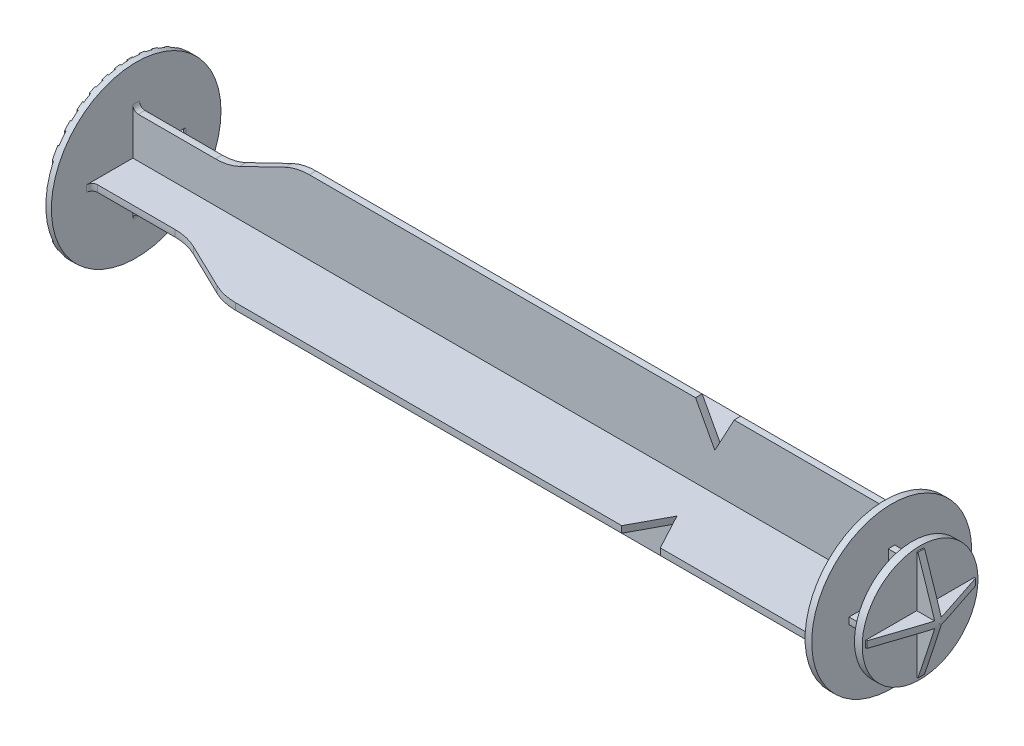
from build123d import *

# Parameters (mm, degrees)
SKETCH2_OUTSIDE_W   = 63.372
SKETCH2_OUTSIDE_H   = 63.372
CUT_EXTRUDE1_DEPTH  = 135.75
SKETCH3_OUTSIDE_W   = 63.372
SKETCH3_OUTSIDE_H   = 63.372
SKETCH3_OUTSIDE_W_2 = 1
SKETCH3_OUTSIDE_H_2 = 30.733735536
CUT_EXTRUDE2_DEPTH  = 0.2
SKETCH4_OUTSIDE_W   = 63.372
SKETCH4_OUTSIDE_H   = 63.372
CUT_EXTRUDE3_DEPTH  = 3.75
SKETCH5_OUTSIDE_W   = 63.372
SKETCH5_OUTSIDE_H   = 63.372
CUT_EXTRUDE4_DEPTH  = 3.5


with BuildPart() as part:
    # Sketch1 → Revolve1 (revolve)
    with BuildSketch(Plane.XY):
        with BuildLine():
            Line((0, 0), (0, 15.375))
            Line((0, 15.375), (1.2, 15.375))
            Line((1.2, 15.375), (1.2, 9))
            ThreePointArc((1.2, 9), (1.492893219, 8.292893219), (2.2, 8))
            Line((2.2, 8), (16.2, 8))
            ThreePointArc((16.2, 8), (18.430707535, 8.251977437), (20.548997476, 8.995211221))
            Line((20.548997476, 8.995211221), (28.851002524, 13.004788779))
            ThreePointArc((28.851002524, 13.004788779), (30.969292465, 13.748022563), (33.2, 14))
            Line((33.2, 14), (103.2, 14))
            Line((103.2, 14), (106.7, 7.5))
            Line((106.7, 7.5), (110.2, 14))
            Line((110.2, 14), (136.95, 14))
            Line((136.95, 14), (136.95, 14.5))
            Line((136.95, 14.5), (138.15, 14.5))
            Line((138.15, 14.5), (138.15, 7.75))
            Line((138.15, 7.75), (141.9, 7.75))
            Line((141.9, 7.75), (141.9, 10.5))
            Line((141.9, 10.5), (143.3, 10.5))
            Line((143.3, 10.5), (146.8, 0))
            Line((146.8, 0), (0, 0))
        make_face()
    revolve(axis=Axis((146.8, 0, 0), (-1, 0, 0)))

    # Sketch2 outside → Cut-Extrude1 (cut)
    with BuildSketch(Plane(origin=(1.2, 0, 0), x_dir=(0, 0, -1), z_dir=(1, 0, 0))):
        Rectangle(SKETCH2_OUTSIDE_W, SKETCH2_OUTSIDE_H)
        with BuildLine():
            Line((-0.6, 15.363288222), (-0.6, 0.6))
            Line((-0.6, 0.6), (-15.363288222, 0.6))
            ThreePointArc((-15.363288222, 0.6), (-15.375, 0), (-15.363288222, -0.6))
            Line((-15.363288222, -0.6), (-0.6, -0.6))
            Line((-0.6, -0.6), (-0.6, -15.363288222))
            ThreePointArc((-0.6, -15.363288222), (0, -15.375), (0.6, -15.363288222))
            Line((0.6, -15.363288222), (0.6, -0.6))
            Line((0.6, -0.6), (15.363288222, -0.6))
            ThreePointArc((15.363288222, -0.6), (15.375, 0), (15.363288222, 0.6))
            Line((15.363288222, 0.6), (0.6, 0.6))
            Line((0.6, 0.6), (0.6, 15.363288222))
            ThreePointArc((0.6, 15.363288222), (0, 15.375), (-0.6, 15.363288222))
        make_face(mode=Mode.SUBTRACT)
    extrude(amount=CUT_EXTRUDE1_DEPTH, mode=Mode.SUBTRACT)

    # Sketch3 outside → Cut-Extrude2 (cut)
    with BuildSketch(Plane.ZY):
        Rectangle(SKETCH3_OUTSIDE_W, SKETCH3_OUTSIDE_H)
        with Locations((2.25, 0)):
            Rectangle(SKETCH3_OUTSIDE_W_2, SKETCH3_OUTSIDE_H_2, mode=Mode.SUBTRACT)
        Rectangle(SKETCH3_OUTSIDE_W_2, SKETCH3_OUTSIDE_H_2, mode=Mode.SUBTRACT)
        with Locations((4.5, 0)):
            Rectangle(SKETCH3_OUTSIDE_W_2, SKETCH3_OUTSIDE_H_2, mode=Mode.SUBTRACT)
        with Locations((6.75, 0)):
            Rectangle(SKETCH3_OUTSIDE_W_2, SKETCH3_OUTSIDE_H_2, mode=Mode.SUBTRACT)
        with Locations((9, 0)):
            Rectangle(SKETCH3_OUTSIDE_W_2, SKETCH3_OUTSIDE_H_2, mode=Mode.SUBTRACT)
        with Locations((11.25, 0)):
            Rectangle(SKETCH3_OUTSIDE_W_2, SKETCH3_OUTSIDE_H_2, mode=Mode.SUBTRACT)
        with Locations((13.5, 0)):
            Rectangle(SKETCH3_OUTSIDE_W_2, SKETCH3_OUTSIDE_H_2, mode=Mode.SUBTRACT)
        with Locations((-2.25, 0)):
            Rectangle(SKETCH3_OUTSIDE_W_2, SKETCH3_OUTSIDE_H_2, mode=Mode.SUBTRACT)
        with Locations((-4.5, 0)):
            Rectangle(SKETCH3_OUTSIDE_W_2, SKETCH3_OUTSIDE_H_2, mode=Mode.SUBTRACT)
        with Locations((-6.75, 0)):
            Rectangle(SKETCH3_OUTSIDE_W_2, SKETCH3_OUTSIDE_H_2, mode=Mode.SUBTRACT)
        with Locations((-9, 0)):
            Rectangle(SKETCH3_OUTSIDE_W_2, SKETCH3_OUTSIDE_H_2, mode=Mode.SUBTRACT)
        with Locations((-11.25, 0)):
            Rectangle(SKETCH3_OUTSIDE_W_2, SKETCH3_OUTSIDE_H_2, mode=Mode.SUBTRACT)
        with Locations((-13.5, 0)):
            Rectangle(SKETCH3_OUTSIDE_W_2, SKETCH3_OUTSIDE_H_2, mode=Mode.SUBTRACT)
    extrude(amount=-CUT_EXTRUDE2_DEPTH, mode=Mode.SUBTRACT)

    # Sketch4 outside → Cut-Extrude3 (cut)
    with BuildSketch(Plane(origin=(138.15, 0, 0), x_dir=(0, 0, -1), z_dir=(1, 0, 0))):
        Rectangle(SKETCH4_OUTSIDE_W, SKETCH4_OUTSIDE_H)
        with BuildLine():
            Line((0.6, 0.6), (0.6, 15.363288222))
            ThreePointArc((0.6, 15.363288222), (0, 15.375), (-0.6, 15.363288222))
            Line((-0.6, 15.363288222), (-0.6, 0.6))
            Line((-0.6, 0.6), (-15.363288222, 0.6))
            ThreePointArc((-15.363288222, 0.6), (-15.375, 0), (-15.363288222, -0.6))
            Line((-15.363288222, -0.6), (-0.6, -0.6))
            Line((-0.6, -0.6), (-0.6, -15.363288222))
            ThreePointArc((-0.6, -15.363288222), (0, -15.375), (0.6, -15.363288222))
            Line((0.6, -15.363288222), (0.6, -0.6))
            Line((0.6, -0.6), (15.363288222, -0.6))
            ThreePointArc((15.363288222, -0.6), (15.375, 0), (15.363288222, 0.6))
            Line((15.363288222, 0.6), (0.6, 0.6))
        make_face(mode=Mode.SUBTRACT)
    extrude(amount=CUT_EXTRUDE3_DEPTH, mode=Mode.SUBTRACT)

    # Sketch5 outside → Cut-Extrude4 (cut)
    with BuildSketch(Plane(origin=(146.8, 0, 0), x_dir=(0, 0, -1), z_dir=(1, 0, 0))):
        Rectangle(SKETCH5_OUTSIDE_W, SKETCH5_OUTSIDE_H)
        with BuildLine():
            Line((0.6, 0.6), (0.6, 9.856755298))
            ThreePointArc((0.6, 9.856755298), (0, 9.875), (-0.6, 9.856755298))
            Line((-0.6, 9.856755298), (-0.6, 0.6))
            Line((-0.6, 0.6), (-9.856755298, 0.6))
            ThreePointArc((-9.856755298, 0.6), (-9.875, 0), (-9.856755298, -0.6))
            Line((-9.856755298, -0.6), (-0.6, -0.6))
            Line((-0.6, -0.6), (-0.6, -9.856755298))
            ThreePointArc((-0.6, -9.856755298), (0, -9.875), (0.6, -9.856755298))
            Line((0.6, -9.856755298), (0.6, -0.6))
            Line((0.6, -0.6), (9.856755298, -0.6))
            ThreePointArc((9.856755298, -0.6), (9.875, 0), (9.856755298, 0.6))
            Line((9.856755298, 0.6), (0.6, 0.6))
        make_face(mode=Mode.SUBTRACT)
    extrude(amount=-CUT_EXTRUDE4_DEPTH, mode=Mode.SUBTRACT)


solid = part.part
